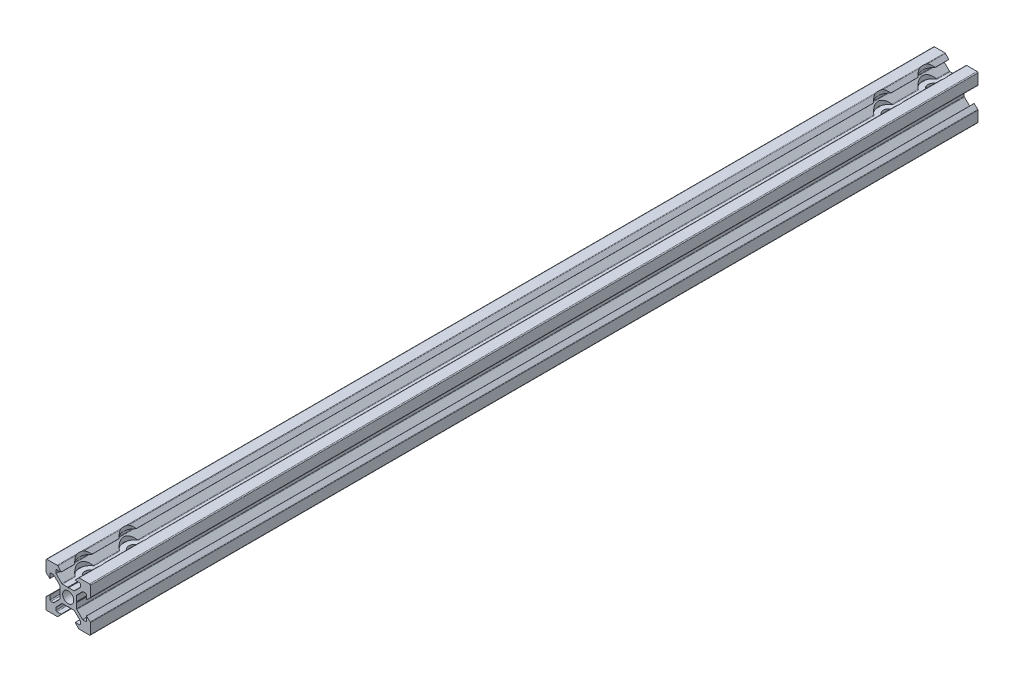
from build123d import *

# Parameters (mm, degrees)
SKETCH_1_R                  = 2
EXTRUDE_1_DEPTH             = 400
HOLE_WIZARD_5_2_5_2_1_D     = 5.2
HOLE_WIZARD_10_0_10_1_D     = 10
HOLE_WIZARD_10_0_10_1_DEPTH = 6.2
HOLE_WIZARD_5_0_5_1_D       = 5
HOLE_WIZARD_5_0_5_1_DEPTH   = 10
HOLE_WIZARD_5_0_5_1_TIP     = 1.502151548
HOLE_WIZARD_5_0_5_2_D       = 5
HOLE_WIZARD_5_0_5_2_DEPTH   = 10
HOLE_WIZARD_5_0_5_2_TIP     = 1.502151548


with BuildPart() as part:
    # 草图1 → 凸台-拉伸1 (new body)
    with BuildSketch(Plane.XY):
        with BuildLine():
            Line((0.2, 3.8), (2.573654403, 3.8))
            ThreePointArc((2.573654403, 3.8), (2.726727776, 3.830448187), (2.856497116, 3.917157288))
            Line((2.856497116, 3.917157288), (5.382842712, 6.443502884))
            ThreePointArc((5.382842712, 6.443502884), (5.469551813, 6.573272224), (5.5, 6.726345597))
            Line((5.5, 6.726345597), (5.5, 7.8))
            ThreePointArc((5.5, 7.8), (5.382842712, 8.082842712), (5.1, 8.2))
            Line((5.1, 8.2), (3.2, 8.2))
            Line((3.2, 8.2), (3.16812307, 8.273206881))
            Line((3.16812307, 8.273206881), (4.656346981, 9.872492278))
            ThreePointArc((4.656346981, 9.872492278), (4.789482474, 9.966740311), (4.949174504, 10))
            Line((4.949174504, 10), (9.6, 10))
            ThreePointArc((9.6, 10), (9.882842712, 9.882842712), (10, 9.6))
            Line((10, 9.6), (10, 4.949174504))
            ThreePointArc((10, 4.949174504), (9.966740311, 4.789482474), (9.872492278, 4.656346981))
            Line((9.872492278, 4.656346981), (8.273206881, 3.16812307))
            Line((8.273206881, 3.16812307), (8.2, 3.2))
            Line((8.2, 3.2), (8.2, 5.1))
            ThreePointArc((8.2, 5.1), (8.082842712, 5.382842712), (7.8, 5.5))
            Line((7.8, 5.5), (6.726345597, 5.5))
            ThreePointArc((6.726345597, 5.5), (6.573272224, 5.469551813), (6.443502884, 5.382842712))
            Line((6.443502884, 5.382842712), (3.917157288, 2.856497116))
            ThreePointArc((3.917157288, 2.856497116), (3.830448187, 2.726727776), (3.8, 2.573654403))
            Line((3.8, 2.573654403), (3.8, 0.2))
            Line((3.8, 0.2), (3.6, 0))
            Line((3.6, 0), (3.8, -0.2))
            Line((3.8, -0.2), (3.8, -2.573654403))
            ThreePointArc((3.8, -2.573654403), (3.830448187, -2.726727776), (3.917157288, -2.856497116))
            Line((3.917157288, -2.856497116), (6.443502885, -5.382842712))
            ThreePointArc((6.443502885, -5.382842712), (6.573272224, -5.469551813), (6.726345597, -5.5))
            Line((6.726345597, -5.5), (7.8, -5.5))
            ThreePointArc((7.8, -5.5), (8.082842713, -5.382842712), (8.2, -5.1))
            Line((8.2, -5.1), (8.2, -3.2))
            Line((8.2, -3.2), (8.273206881, -3.16812307))
            Line((8.273206881, -3.16812307), (9.872492279, -4.656346981))
            ThreePointArc((9.872492279, -4.656346981), (9.966740311, -4.789482474), (10, -4.949174504))
            Line((10, -4.949174504), (10, -9.6))
            ThreePointArc((10, -9.6), (9.882842713, -9.882842712), (9.6, -10))
            Line((9.6, -10), (4.949174504, -10))
            ThreePointArc((4.949174504, -10), (4.789482475, -9.966740311), (4.656346981, -9.872492278))
            Line((4.656346981, -9.872492278), (3.16812307, -8.273206881))
            Line((3.16812307, -8.273206881), (3.2, -8.2))
            Line((3.2, -8.2), (5.1, -8.2))
            ThreePointArc((5.1, -8.2), (5.382842713, -8.082842712), (5.5, -7.8))
            Line((5.5, -7.8), (5.5, -6.726345597))
            ThreePointArc((5.5, -6.726345597), (5.469551813, -6.573272224), (5.382842713, -6.443502884))
            Line((5.382842713, -6.443502884), (2.856497116, -3.917157288))
            ThreePointArc((2.856497116, -3.917157288), (2.726727777, -3.830448187), (2.573654404, -3.8))
            Line((2.573654404, -3.8), (0.2, -3.8))
            Line((0.2, -3.8), (0, -3.6))
            Line((0, -3.6), (-0.2, -3.8))
            Line((-0.2, -3.8), (-2.573654403, -3.8))
            ThreePointArc((-2.573654403, -3.8), (-2.726727776, -3.830448187), (-2.856497115, -3.917157288))
            Line((-2.856497115, -3.917157288), (-5.382842712, -6.443502885))
            ThreePointArc((-5.382842712, -6.443502885), (-5.469551813, -6.573272224), (-5.5, -6.726345597))
            Line((-5.5, -6.726345597), (-5.5, -7.8))
            ThreePointArc((-5.5, -7.8), (-5.382842712, -8.082842713), (-5.1, -8.2))
            Line((-5.1, -8.2), (-3.2, -8.2))
            Line((-3.2, -8.2), (-3.168123069, -8.273206881))
            Line((-3.168123069, -8.273206881), (-4.656346981, -9.872492279))
            ThreePointArc((-4.656346981, -9.872492279), (-4.789482474, -9.966740311), (-4.949174504, -10))
            Line((-4.949174504, -10), (-9.6, -10))
            ThreePointArc((-9.6, -10), (-9.882842712, -9.882842713), (-10, -9.6))
            Line((-10, -9.6), (-10, -4.949174504))
            ThreePointArc((-10, -4.949174504), (-9.966740311, -4.789482475), (-9.872492278, -4.656346981))
            Line((-9.872492278, -4.656346981), (-8.27320688, -3.16812307))
            Line((-8.27320688, -3.16812307), (-8.2, -3.2))
            Line((-8.2, -3.2), (-8.2, -5.1))
            ThreePointArc((-8.2, -5.1), (-8.082842712, -5.382842713), (-7.8, -5.5))
            Line((-7.8, -5.5), (-6.726345596, -5.5))
            ThreePointArc((-6.726345596, -5.5), (-6.573272223, -5.469551813), (-6.443502884, -5.382842713))
            Line((-6.443502884, -5.382842713), (-3.917157287, -2.856497116))
            ThreePointArc((-3.917157287, -2.856497116), (-3.830448187, -2.726727777), (-3.8, -2.573654404))
            Line((-3.8, -2.573654404), (-3.8, -0.2))
            Line((-3.8, -0.2), (-3.6, 0))
            Line((-3.6, 0), (-3.8, 0.2))
            Line((-3.8, 0.2), (-3.8, 2.573654403))
            ThreePointArc((-3.8, 2.573654403), (-3.830448187, 2.726727776), (-3.917157288, 2.856497115))
            Line((-3.917157288, 2.856497115), (-6.443502884, 5.382842712))
            ThreePointArc((-6.443502884, 5.382842712), (-6.573272224, 5.469551813), (-6.726345597, 5.5))
            Line((-6.726345597, 5.5), (-7.8, 5.5))
            ThreePointArc((-7.8, 5.5), (-8.082842712, 5.382842712), (-8.2, 5.1))
            Line((-8.2, 5.1), (-8.2, 3.2))
            Line((-8.2, 3.2), (-8.273206881, 3.168123069))
            Line((-8.273206881, 3.168123069), (-9.872492278, 4.656346981))
            ThreePointArc((-9.872492278, 4.656346981), (-9.966740311, 4.789482474), (-10, 4.949174504))
            Line((-10, 4.949174504), (-10, 9.6))
            ThreePointArc((-10, 9.6), (-9.882842712, 9.882842712), (-9.6, 10))
            Line((-9.6, 10), (-4.949174504, 10))
            ThreePointArc((-4.949174504, 10), (-4.789482474, 9.966740311), (-4.656346981, 9.872492278))
            Line((-4.656346981, 9.872492278), (-3.16812307, 8.27320688))
            Line((-3.16812307, 8.27320688), (-3.2, 8.2))
            Line((-3.2, 8.2), (-5.1, 8.2))
            ThreePointArc((-5.1, 8.2), (-5.382842712, 8.082842712), (-5.5, 7.8))
            Line((-5.5, 7.8), (-5.5, 6.726345596))
            ThreePointArc((-5.5, 6.726345596), (-5.469551813, 6.573272223), (-5.382842712, 6.443502884))
            Line((-5.382842712, 6.443502884), (-2.856497116, 3.917157287))
            ThreePointArc((-2.856497116, 3.917157287), (-2.726727776, 3.830448187), (-2.573654403, 3.8))
            Line((-2.573654403, 3.8), (-0.2, 3.8))
            Line((-0.2, 3.8), (0, 3.6))
            Line((0, 3.6), (0.2, 3.8))
        make_face()
        Circle(SKETCH_1_R, mode=Mode.SUBTRACT)
    extrude(amount=EXTRUDE_1_DEPTH)

    # Ø5.2 (5.2) 直径孔1 (through all)
    with Locations(Plane(origin=(0, 10, 0), x_dir=(1, 0, 0), z_dir=(0, 1, 0))):
        with Locations((0, -10), (0, -30), (0, -390), (0, -370)):
            Hole(HOLE_WIZARD_5_2_5_2_1_D / 2)

    # Ø10.0 (10) 直径孔1
    with Locations(Plane(origin=(0, 10, 0), x_dir=(1, 0, 0), z_dir=(0, 1, 0))):
        with Locations((0, -390), (0, -370), (0, -30), (0, -10)):
            Hole(HOLE_WIZARD_10_0_10_1_D / 2, depth=HOLE_WIZARD_10_0_10_1_DEPTH)

    # Ø5.0 (5) 直径孔1
    with Locations(Plane.XY.offset(400)):
        with Locations((0, 0)):
            Hole(HOLE_WIZARD_5_0_5_1_D / 2, depth=HOLE_WIZARD_5_0_5_1_DEPTH)
            with Locations((0, 0, -(HOLE_WIZARD_5_0_5_1_DEPTH + HOLE_WIZARD_5_0_5_1_TIP / 2))):  # 118° drill point
                Cone(0, HOLE_WIZARD_5_0_5_1_D / 2, HOLE_WIZARD_5_0_5_1_TIP, mode=Mode.SUBTRACT)

    # Ø5.0 (5) 直径孔2
    with Locations(Plane(origin=(0, 0, 0), x_dir=(-1, 0, 0), z_dir=(0, 0, -1))):
        with Locations((0, 0)):
            Hole(HOLE_WIZARD_5_0_5_2_D / 2, depth=HOLE_WIZARD_5_0_5_2_DEPTH)
            with Locations((0, 0, -(HOLE_WIZARD_5_0_5_2_DEPTH + HOLE_WIZARD_5_0_5_2_TIP / 2))):  # 118° drill point
                Cone(0, HOLE_WIZARD_5_0_5_2_D / 2, HOLE_WIZARD_5_0_5_2_TIP, mode=Mode.SUBTRACT)


solid = part.part
